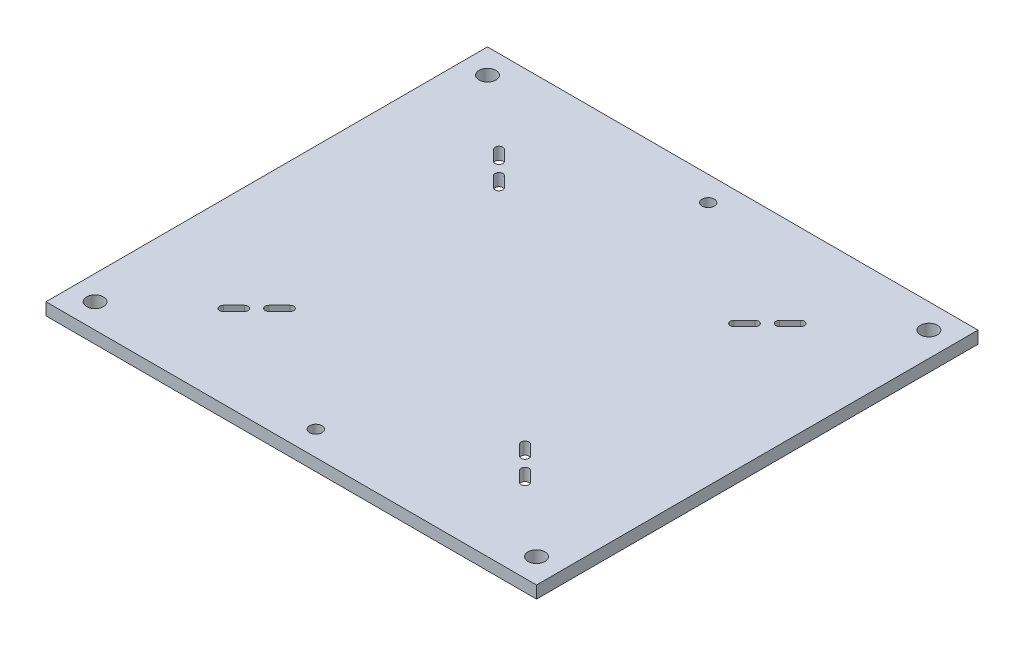
from build123d import *

# Parameters (mm, degrees)
SKETCH1_W                            = 254
SKETCH1_H                            = 228.6
BASE_PLATE_DEPTH                     = 6.35
SLOTS_DEPTH                          = 7.35
FEET_CONNECTION_HOLE_D               = 8.7376
HOLE_FOR_10_BLIND_FASTENERS_B_BS_1_D = 6.35


with BuildPart() as part:
    # Sketch1 → base plate (new body)
    with BuildSketch(Plane(origin=(0, 0, 0), x_dir=(1, 0, 0), z_dir=(0, 1, 0))):
        with Locations((127, -114.3)):
            Rectangle(SKETCH1_W, SKETCH1_H)
    extrude(amount=-BASE_PLATE_DEPTH)

    # Sketch3 → slots (cut, through all)
    with BuildSketch(Plane(origin=(0, 0, 0), x_dir=(1, 0, 0), z_dir=(0, 1, 0))):
        with BuildLine():
            ThreePointArc((55.724612456, -46.94618524), (55.724612456, -49.774612456), (52.89618524, -49.774612456))
            Line((52.89618524, -49.774612456), (47.508031568, -44.386458783))
            ThreePointArc((47.508031568, -44.386458783), (47.508031568, -41.558031568), (50.336458783, -41.558031568))
            Line((50.336458783, -41.558031568), (55.724612456, -46.94618524))
        make_face()
        with BuildLine():
            Line((203.663541217, -41.558031568), (198.275387544, -46.94618524))
            ThreePointArc((198.275387544, -46.94618524), (198.275387544, -49.774612456), (201.10381476, -49.774612456))
            Line((201.10381476, -49.774612456), (206.491968432, -44.386458783))
            ThreePointArc((206.491968432, -44.386458783), (206.491968432, -41.558031568), (203.663541217, -41.558031568))
        make_face()
        with BuildLine():
            Line((189.295131423, -61.583295792), (194.683285096, -56.195142119))
            ThreePointArc((194.683285096, -56.195142119), (194.683285096, -53.366714904), (191.854857881, -53.366714904))
            Line((191.854857881, -53.366714904), (186.466704208, -58.754868577))
            ThreePointArc((186.466704208, -58.754868577), (186.466704208, -61.583295792), (189.295131423, -61.583295792))
        make_face()
        with BuildLine():
            ThreePointArc((194.683285096, -172.404857881), (194.683285096, -175.233285096), (191.854857881, -175.233285096))
            Line((191.854857881, -175.233285096), (186.466704208, -169.845131423))
            ThreePointArc((186.466704208, -169.845131423), (186.466704208, -167.016704208), (189.295131423, -167.016704208))
            Line((189.295131423, -167.016704208), (194.683285096, -172.404857881))
        make_face()
        with BuildLine():
            ThreePointArc((198.275387544, -181.65381476), (198.275387544, -178.825387544), (201.10381476, -178.825387544))
            Line((201.10381476, -178.825387544), (206.491968432, -184.213541217))
            ThreePointArc((206.491968432, -184.213541217), (206.491968432, -187.041968432), (203.663541217, -187.041968432))
            Line((203.663541217, -187.041968432), (198.275387544, -181.65381476))
        make_face()
        with BuildLine():
            Line((50.336458783, -187.041968432), (55.724612456, -181.65381476))
            ThreePointArc((55.724612456, -181.65381476), (55.724612456, -178.825387544), (52.89618524, -178.825387544))
            Line((52.89618524, -178.825387544), (47.508031568, -184.213541217))
            ThreePointArc((47.508031568, -184.213541217), (47.508031568, -187.041968432), (50.336458783, -187.041968432))
        make_face()
        with BuildLine():
            Line((64.704868577, -167.016704208), (59.316714904, -172.404857881))
            ThreePointArc((59.316714904, -172.404857881), (59.316714904, -175.233285096), (62.145142119, -175.233285096))
            Line((62.145142119, -175.233285096), (67.533295792, -169.845131423))
            ThreePointArc((67.533295792, -169.845131423), (67.533295792, -167.016704208), (64.704868577, -167.016704208))
        make_face()
        with BuildLine():
            Line((64.704868577, -61.583295792), (59.316714904, -56.195142119))
            ThreePointArc((59.316714904, -56.195142119), (59.316714904, -53.366714904), (62.145142119, -53.366714904))
            Line((62.145142119, -53.366714904), (67.533295792, -58.754868577))
            ThreePointArc((67.533295792, -58.754868577), (67.533295792, -61.583295792), (64.704868577, -61.583295792))
        make_face()
    extrude(amount=-SLOTS_DEPTH, mode=Mode.SUBTRACT)

    # Feet connection hole (through all)
    with Locations(Plane(origin=(0, 0, 0), x_dir=(1, 0, 0), z_dir=(0, 1, 0))):
        with Locations((12.7, -215.9), (241.3, -12.7), (12.7, -12.7), (241.3, -215.9)):
            Hole(FEET_CONNECTION_HOLE_D / 2)

    # Hole for #10 Blind Fasteners (B,BS)1 (through all)
    with Locations(Plane(origin=(0, 0, 0), x_dir=(1, 0, 0), z_dir=(0, 1, 0))):
        with Locations((127, -215.9), (127, -12.7)):
            Hole(HOLE_FOR_10_BLIND_FASTENERS_B_BS_1_D / 2)


solid = part.part
